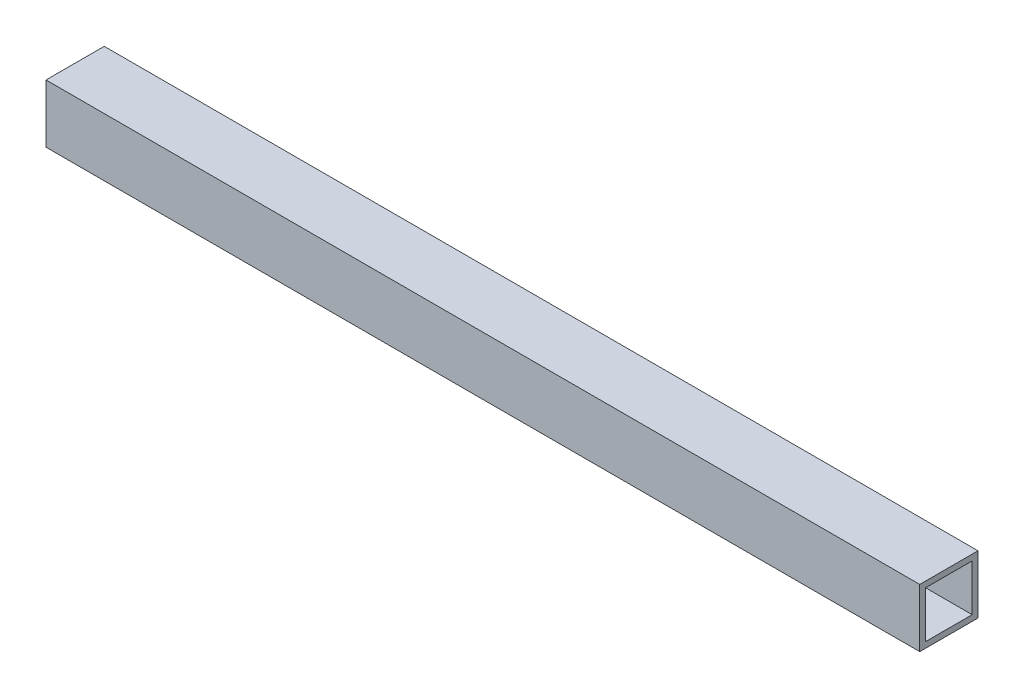
from build123d import *

# Parameters (mm, degrees)
SKETCH1_W           = 10
SKETCH1_H           = 10
SKETCH1_W_2         = 8
SKETCH1_H_2         = 8
BOSS_EXTRUDE1_DEPTH = 150


with BuildPart() as part:
    # Sketch1 → Boss-Extrude1 (new body)
    with BuildSketch(Plane(origin=(0, 0, 0), x_dir=(0, 0, -1), z_dir=(1, 0, 0))):
        Rectangle(SKETCH1_W, SKETCH1_H)
        Rectangle(SKETCH1_W_2, SKETCH1_H_2, mode=Mode.SUBTRACT)
    extrude(amount=BOSS_EXTRUDE1_DEPTH)


solid = part.part
